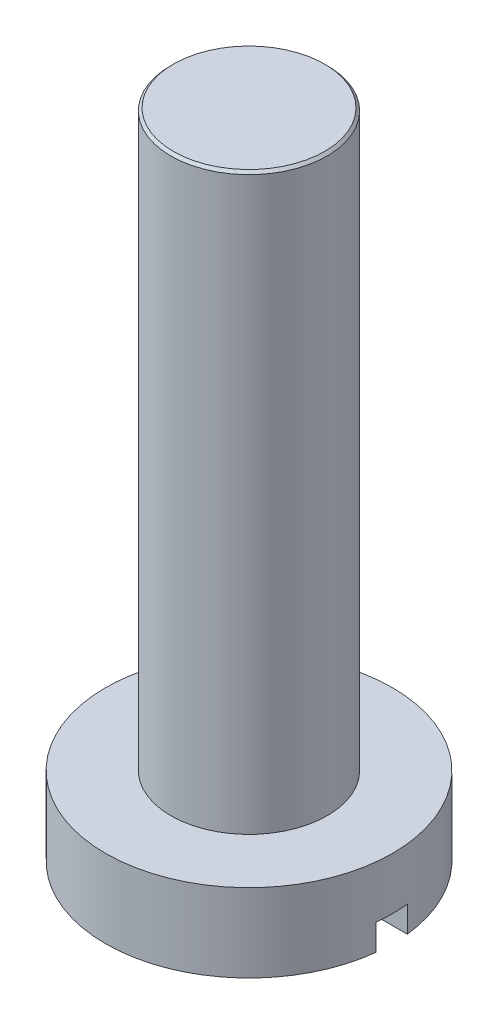
from build123d import *

# Parameters (mm, degrees)
SKETCH1_R           = 1.5
BOSS_EXTRUDE1_DEPTH = 11
SKETCH2_R           = 2.75
BOSS_EXTRUDE2_DEPTH = 1.5
SKETCH3_W           = 8.196351728
SKETCH3_H           = 0.6
CUT_EXTRUDE1_DEPTH  = 0.5
CHAMFER1_SIZE       = 0.05


with BuildPart() as part:
    # Sketch1 → Boss-Extrude1 (new body)
    with BuildSketch(Plane(origin=(0, 0, 0), x_dir=(1, 0, 0), z_dir=(0, 1, 0))):
        Circle(SKETCH1_R)
    extrude(amount=BOSS_EXTRUDE1_DEPTH)

    # Chamfer1
    chamfer1_edges = [part.edges().sort_by_distance(p)[0] for p in [
        (-1.5, 11, 0),
    ]]
    chamfer(chamfer1_edges, length=CHAMFER1_SIZE)


with BuildPart() as body_2:
    # Sketch2 → Boss-Extrude2 (new body)
    with BuildSketch(Plane.XZ):
        Circle(SKETCH2_R)
    extrude(amount=BOSS_EXTRUDE2_DEPTH)

    # Sketch3 → Cut-Extrude1 (cut)
    with BuildSketch(Plane.XZ.offset(1.5)):
        Rectangle(SKETCH3_W, SKETCH3_H)
    extrude(amount=-CUT_EXTRUDE1_DEPTH, mode=Mode.SUBTRACT)


solid = Compound([part.part, body_2.part])
